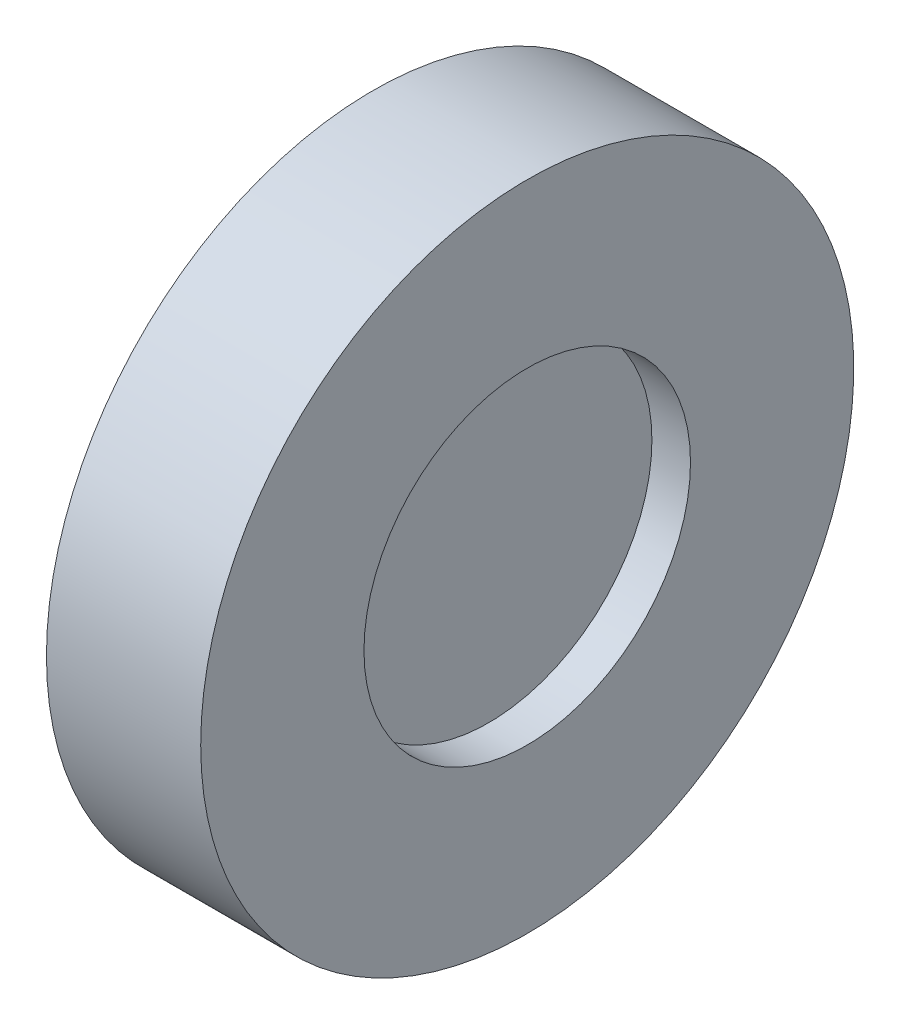
from build123d import *

# Parameters (mm, degrees)
SKETCH_1_W = 3
SKETCH_1_H = 6.35
SKETCH_4_W = 6
SKETCH_4_H = 6.35


with BuildPart() as part:
    # 草图1 → 旋转2 (revolve)
    with BuildSketch(Plane.XY, mode=Mode.PRIVATE) as revolve_2_sk:
        with Locations((0, 3.175)):
            Rectangle(SKETCH_1_W, SKETCH_1_H)
    revolve(revolve_2_sk.sketch.rotate(Axis((-1.5, 0, 0), (1, 0, 0)), 90), axis=Axis((-1.5, 0, 0), (1, 0, 0)))  # turned: the seam where the file's is

    # 草图4 → 旋转3 (revolve)
    with BuildSketch(Plane.XY, mode=Mode.PRIVATE) as revolve_3_sk:
        with Locations((0, 9.525)):
            Rectangle(SKETCH_4_W, SKETCH_4_H)
    revolve(revolve_3_sk.sketch.rotate(Axis((-1.614212419, 0, 0), (1, 0, 0)), 90), axis=Axis((-1.614212419, 0, 0), (1, 0, 0)))  # turned: the seam where the file's is


solid = part.part
